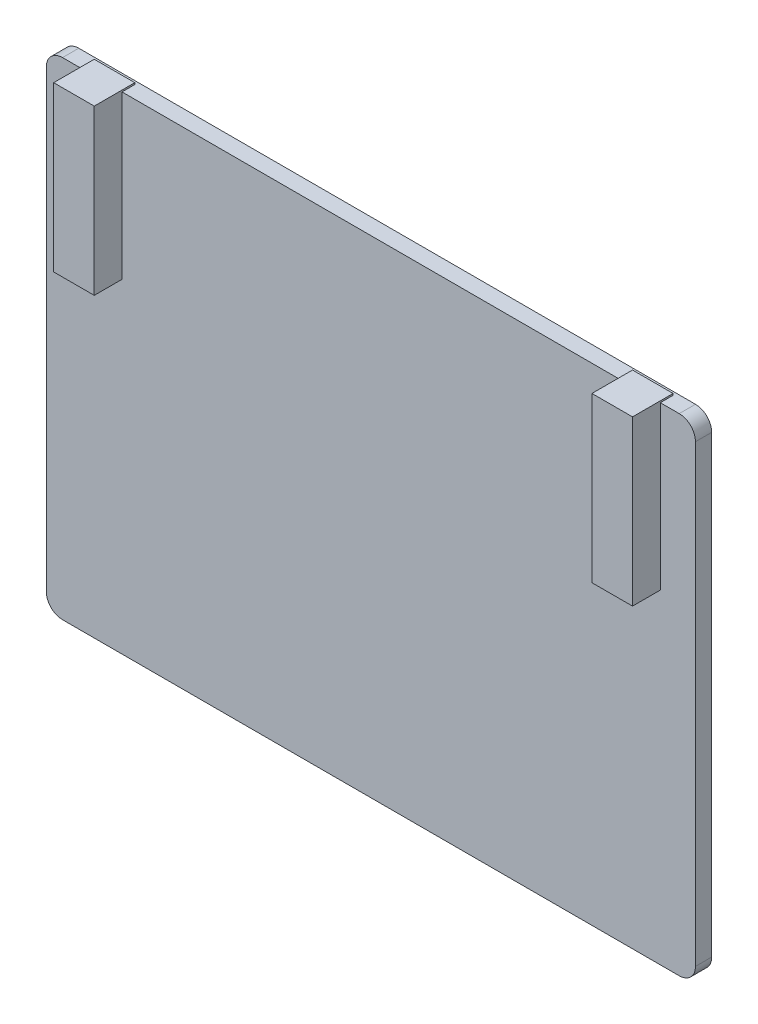
from build123d import *

# Parameters (mm, degrees)
SKETCH1_W           = 101.6
SKETCH1_H           = 76.2
BOSS_EXTRUDE1_DEPTH = 2.54
SKETCH2_R           = 1.5875
SKETCH2_R_2         = 1.3335
BOSS_EXTRUDE2_DEPTH = 25.4
BOSS_EXTRUDE3_START = 0.254
SKETCH3_R           = 1.5875
BOSS_EXTRUDE3_DEPTH = 0.254
FILLET1_R           = 2.54
BOSS_EXTRUDE4_START = -25.654
SKETCH4_W           = 6.35
SKETCH4_H           = 6.35
BOSS_EXTRUDE4_DEPTH = 25.654
SKETCH5_R           = 2.54
CUT_EXTRUDE1_DEPTH  = 24.13


with BuildPart() as part:
    # Sketch1 → Boss-Extrude1 (new body)
    with BuildSketch(Plane.XY):
        Rectangle(SKETCH1_W, SKETCH1_H)
    extrude(amount=BOSS_EXTRUDE1_DEPTH)

    # Sketch2 → Boss-Extrude2 (add)
    # profile 1 of 2: a face of its own
    with BuildSketch(Plane(origin=(0, 38.1, 0), x_dir=(1, 0, 0), z_dir=(0, 1, 0))):
        with Locations((-42.123995, -3.71475)):
            Circle(SKETCH2_R)
        with Locations((-42.123995, -3.71475)):
            Circle(SKETCH2_R_2, mode=Mode.SUBTRACT)
    # profile 2 of 2: a face of its own
    with BuildSketch(Plane(origin=(0, 38.1, 0), x_dir=(1, 0, 0), z_dir=(0, 1, 0))):
        with Locations((42.123995, -3.71475)):
            Circle(SKETCH2_R)
        with Locations((42.123995, -3.71475)):
            Circle(SKETCH2_R_2, mode=Mode.SUBTRACT)
    extrude(amount=-BOSS_EXTRUDE2_DEPTH)

    # Sketch3 → Boss-Extrude3 (add)
    with BuildSketch(Plane(origin=(0, 38.1, 0), x_dir=(1, 0, 0), z_dir=(0, 1, 0)).offset(BOSS_EXTRUDE3_START)):
        with Locations(Location((-42.123995, -3.71475, 0), (0, 0, 270))):
            Circle(SKETCH3_R)
        with Locations(Location((42.123995, -3.71475, 0), (0, 0, 132.26858443))):
            Circle(SKETCH3_R)
    extrude(amount=-BOSS_EXTRUDE3_DEPTH)

    # Fillet1
    fillet1_edges = [part.edges().sort_by_distance(p)[0] for p in [
        (50.8, -38.1, 1.27),
        (-50.8, -38.1, 1.27),
        (-50.8, 38.1, 1.27),
        (50.8, 38.1, 1.27),
    ]]
    fillet(fillet1_edges, radius=FILLET1_R)

    # Sketch4 → Boss-Extrude4 (add)
    with BuildSketch(Plane(origin=(0, 38.354, 0), x_dir=(1, 0, 0), z_dir=(0, 1, 0)).offset(BOSS_EXTRUDE4_START)):
        with Locations((-42.123995, -3.71475)):
            Rectangle(SKETCH4_W, SKETCH4_H)
        with Locations((42.123995, -3.71475)):
            Rectangle(SKETCH4_W, SKETCH4_H)
    extrude(amount=BOSS_EXTRUDE4_DEPTH)

    # Sketch5 → Cut-Extrude1 (cut)
    with BuildSketch(Plane.XZ.offset(-12.7)):
        with Locations(Location((-42.123995, 3.71475, 0), (0, 0, 270))):
            Circle(SKETCH5_R)
        with Locations(Location((42.123995, 3.71475, 0), (0, 0, 270))):
            Circle(SKETCH5_R)
    extrude(amount=-CUT_EXTRUDE1_DEPTH, mode=Mode.SUBTRACT)


solid = part.part
